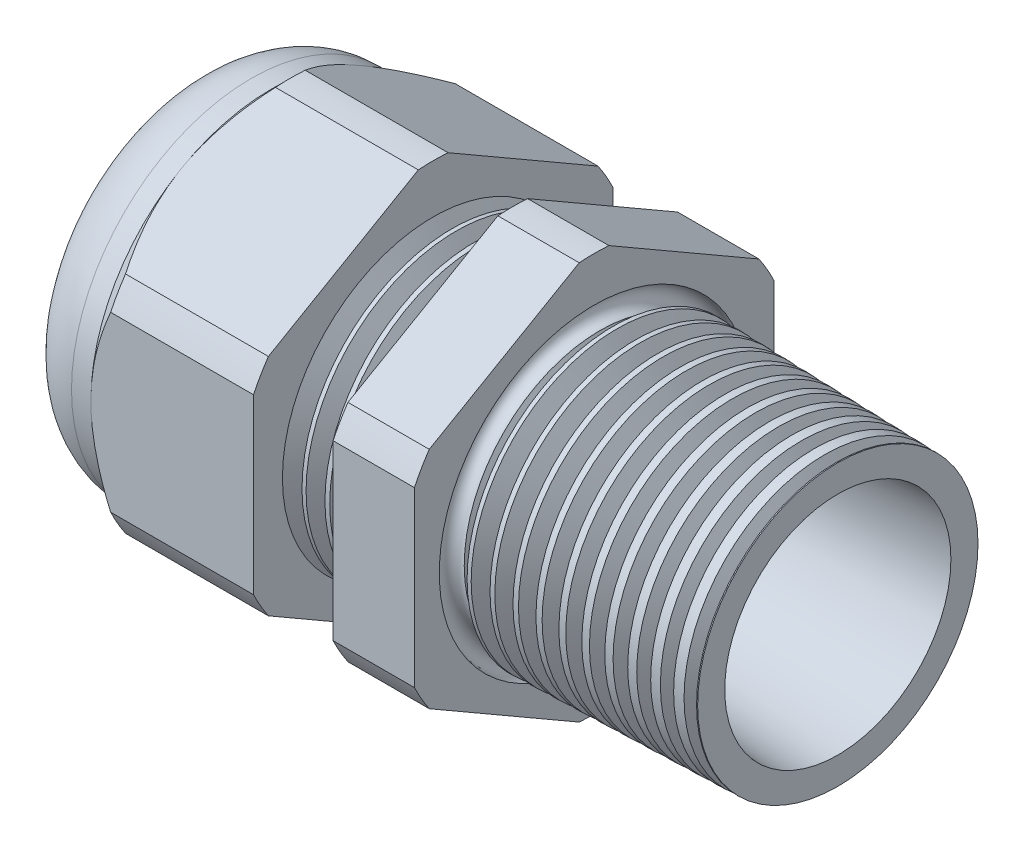
from build123d import *

# Parameters (mm, degrees)
LPATTERN6_COUNT    = 4
LPATTERN6_PITCH    = 1.397
LPATTERN7_COUNT    = 11
LPATTERN7_PITCH    = 1.397
SKETCH12_OUTSIDE_W = 61.024
SKETCH12_OUTSIDE_H = 61.024
CUT_EXTRUDE2_DEPTH = 35.878
FILLET4_R          = 3.81
SKETCH19_OUTSIDE_W = 38.452
SKETCH19_OUTSIDE_H = 40.882
SKETCH19_OUTSIDE_R = 11.049
CUT_EXTRUDE3_DEPTH = 1.999996
CUT_EXTRUDE3_DRAFT = -45
SKETCH28_R         = 0.635


with BuildPart() as part:
    # Sketch10 → Revolve2 (revolve)
    with BuildSketch(Plane.XY, mode=Mode.PRIVATE) as revolve2_sk:
        Polygon((-27.766, 5.588), (-17.766, 5.588), (7.112, 6.95325), (7.112, 8.619546643), (-7.874, 9.011968864), (-7.874, 22.098), (-12.874, 22.098), (-12.874, 9.142898472), (-17.766, 9.271), (-17.766, 22.098), (-27.766, 22.098), (-27.766, 11.049), (-32.766, 11.049), (-32.766, 6.95325), (-27.766, 6.95325), align=None)
    revolve(revolve2_sk.sketch.rotate(Axis((0, 0, 0), (-1, 0, 0)), 90), axis=Axis((0, 0, 0), (-1, 0, 0)))  # turned: the seam where the file's is

    # Sketch26 → Cut-Revolve1 (revolve, cut)
    with BuildSketch(Plane.XY, mode=Mode.PRIVATE) as cut_revolve1_sk:
        Polygon((-17.766, 9.271), (-16.593226271, 9.240289839), (-17.206208915, 8.239993077), align=None)
    cut_revolve1 = revolve(cut_revolve1_sk.sketch.rotate(Axis((0, 0, 0), (-1, 0, 0)), 90), axis=Axis((0, 0, 0), (-1, 0, 0)), mode=Mode.SUBTRACT)  # turned: the seam where the file's is

    # LPattern6: Cut-Revolve1 ×4
    with Locations(*[(i * LPATTERN6_PITCH, 0, 0) for i in range(1, LPATTERN6_COUNT)]):
        add(cut_revolve1, mode=Mode.SUBTRACT)

    # Sketch27 → Cut-Revolve2 (revolve, cut)
    with BuildSketch(Plane.XY, mode=Mode.PRIVATE) as cut_revolve2_sk:
        Polygon((-7.874, 9.011968864), (-6.701226271, 8.981258703), (-7.314208915, 7.980961941), align=None)
    cut_revolve2 = revolve(cut_revolve2_sk.sketch.rotate(Axis((0, 0, 0), (-1, 0, 0)), 90), axis=Axis((0, 0, 0), (-1, 0, 0)), mode=Mode.SUBTRACT)  # turned: the seam where the file's is

    # LPattern7: Cut-Revolve2 ×11
    with Locations(*[(i * LPATTERN7_PITCH, 0, 0) for i in range(1, LPATTERN7_COUNT)]):
        add(cut_revolve2, mode=Mode.SUBTRACT)

    # Sketch12 outside → Cut-Extrude2 (cut, through all)
    with BuildSketch(Plane.ZY.offset(27.766)):
        Rectangle(SKETCH12_OUTSIDE_W, SKETCH12_OUTSIDE_H)
        with BuildLine():
            Line((-0.914603493, 12.230239676), (-10.134396507, 6.907189697))
            ThreePointArc((-10.134396507, 6.907189697), (-10.621273302, 6.132195), (-11.049, 5.323049978))
            Line((-11.049, 5.323049978), (-11.049, -5.323049978))
            ThreePointArc((-11.049, -5.323049978), (-10.621273302, -6.132195), (-10.134396507, -6.907189697))
            Line((-10.134396507, -6.907189697), (-0.914603493, -12.230239676))
            ThreePointArc((-0.914603493, -12.230239676), (0, -12.26439), (0.914603493, -12.230239676))
            Line((0.914603493, -12.230239676), (10.134396507, -6.907189697))
            ThreePointArc((10.134396507, -6.907189697), (10.621273302, -6.132195), (11.049, -5.323049978))
            Line((11.049, -5.323049978), (11.049, 5.323049978))
            ThreePointArc((11.049, 5.323049978), (10.621273302, 6.132195), (10.134396507, 6.907189697))
            Line((10.134396507, 6.907189697), (0.914603493, 12.230239676))
            ThreePointArc((0.914603493, 12.230239676), (0, 12.26439), (-0.914603493, 12.230239676))
        make_face(mode=Mode.SUBTRACT)
    extrude(amount=-CUT_EXTRUDE2_DEPTH, mode=Mode.SUBTRACT)

    # Fillet4
    fillet4_edges = [part.edges().sort_by_distance(p)[0] for p in [
        (-32.766, 0, 11.049),
    ]]
    fillet(fillet4_edges, radius=FILLET4_R)


with BuildPart() as body_2:
    # Sketch23 → Revolve6 (revolve)
    with BuildSketch(Plane.XY, mode=Mode.PRIVATE) as revolve6_sk:
        with BuildLine():
            Line((-31.7754, 6.95325), (-27.766, 6.95325))
            Line((-27.766, 6.95325), (-27.766, 5.588))
            Line((-27.766, 5.588), (-32.004, 5.588))
            Line((-32.004, 5.588), (-32.004, 6.72465))
            ThreePointArc((-32.004, 6.72465), (-31.93704461, 6.88629461), (-31.7754, 6.95325))
        make_face()
    revolve(revolve6_sk.sketch.rotate(Axis((0, 0, 0), (-1, 0, 0)), 270), axis=Axis((0, 0, 0), (-1, 0, 0)))  # turned: the seam where the file's is


with BuildPart() as cut_extrude3_tool:
    # Sketch19 outside → Cut-Extrude3 (with draft: the straight prism first)
    with BuildSketch(Plane.ZY.offset(27.766)):
        Rectangle(SKETCH19_OUTSIDE_W, SKETCH19_OUTSIDE_H)
        Circle(SKETCH19_OUTSIDE_R, mode=Mode.SUBTRACT)
    extrude(amount=-CUT_EXTRUDE3_DEPTH)
    # Cut-Extrude3: the draft: its side faces are tilted about the plane it starts from
    cut_extrude3_sides = [cut_extrude3_tool.faces().sort_by_distance(p)[0] for p in [
        (-26.766002, -20.441, 0),
        (-26.766002, 0, 19.226),
        (-26.766002, 20.441, 0),
        (-26.766002, 0, -19.226),
        (-26.766002, 0, -11.049),
    ]]
    draft(cut_extrude3_sides, Plane.ZY.offset(27.766), CUT_EXTRUDE3_DRAFT)


with BuildPart() as part_1:
    add(part.part)

    # Cut-Extrude3: cut by cut_extrude3_tool
    add(cut_extrude3_tool.part, mode=Mode.SUBTRACT)

    # Sketch28 → Cut-Revolve3 (revolve, cut)
    with BuildSketch(Plane.XY, mode=Mode.PRIVATE) as cut_revolve3_sk:
        with Locations((-7.8486, -8.884968864)):
            Circle(SKETCH28_R)
    revolve(cut_revolve3_sk.sketch.rotate(Axis((7.112, 0, 0), (-1, 0, 0)), 90), axis=Axis((7.112, 0, 0), (-1, 0, 0)), mode=Mode.SUBTRACT)  # turned: the seam where the file's is


solid = Compound([body_2.part, part_1.part])
